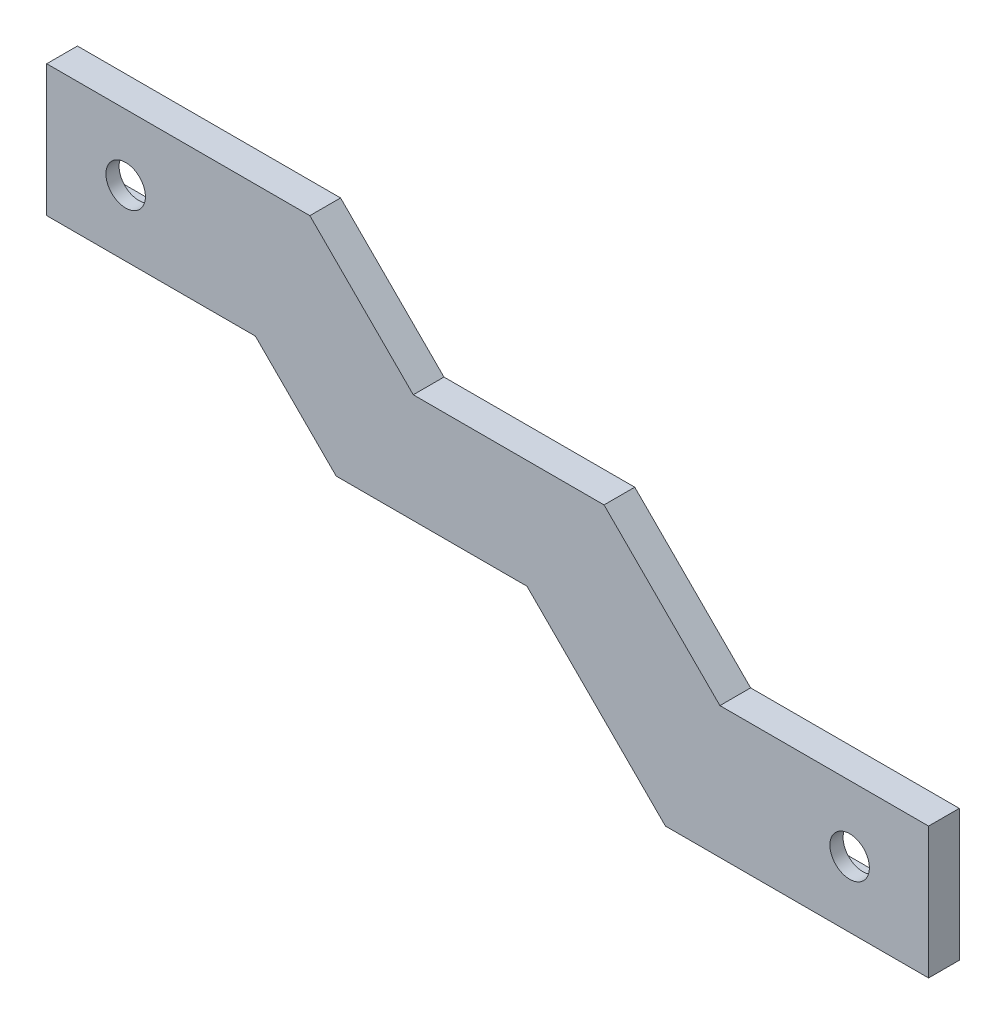
from build123d import *

# Parameters (mm, degrees)
SKETCH_1_W          = 100.539230484
SKETCH_1_H          = 40
SKETCH_1_W_2        = 17
SKETCH_1_H_2        = 7
EXTRUDE_1_DEPTH     = 2
SKETCH_2_W          = 100.539230484
SKETCH_2_H          = 40
SKETCH_2_R          = 2.25
EXTRUDE_2_DEPTH     = 1.5
SKETCH_3_W          = 184.808915215
SKETCH_3_H          = 94.825170589
CUT_EXTRUDE_1_DEPTH = 31.5


with BuildPart() as part:
    # Эскиз1 → Бобышка-Вытянуть1 (new body)
    with BuildSketch(Plane.XY):
        with Locations((62.5, 12.5)):
            Rectangle(SKETCH_1_W, SKETCH_1_H)
        with Locations((24.230384758, 25)):
            Rectangle(SKETCH_1_W_2, SKETCH_1_H_2, mode=Mode.SUBTRACT)
        with Locations((100.769615242, 0)):
            Rectangle(SKETCH_1_W_2, SKETCH_1_H_2, mode=Mode.SUBTRACT)
    extrude(amount=EXTRUDE_1_DEPTH)

    # Эскиз2 → Бобышка-Вытянуть2 (add)
    with BuildSketch(Plane.XY.offset(2)):
        with Locations((62.5, 12.5)):
            Rectangle(SKETCH_2_W, SKETCH_2_H)
        with Locations((21.230384758, 25)):
            Circle(SKETCH_2_R, mode=Mode.SUBTRACT)
        with Locations((103.769615242, 0)):
            Circle(SKETCH_2_R, mode=Mode.SUBTRACT)
    extrude(amount=EXTRUDE_2_DEPTH)

    # Эскиз3 → Вырез-Вытянуть1 (cut)
    with BuildSketch(Plane.XY.offset(3.5)):
        with Locations((81.231416835, 7.831688581)):
            Rectangle(SKETCH_3_W, SKETCH_3_H)
        Polygon((12.230384758, 32.5), (42.230384758, 32.5), (54.020384758, 20.71), (75.769615242, 20.71), (88.979615242, 7.5), (112.769615242, 7.5), (112.769615242, -7.5), (82.769615242, -7.5), (66.982818678, 8.286796564), (45.230384758, 8.286796564), (36.017181322, 17.5), (12.230384758, 17.5), align=None, mode=Mode.SUBTRACT)
    extrude(amount=-CUT_EXTRUDE_1_DEPTH, mode=Mode.SUBTRACT)


solid = part.part
